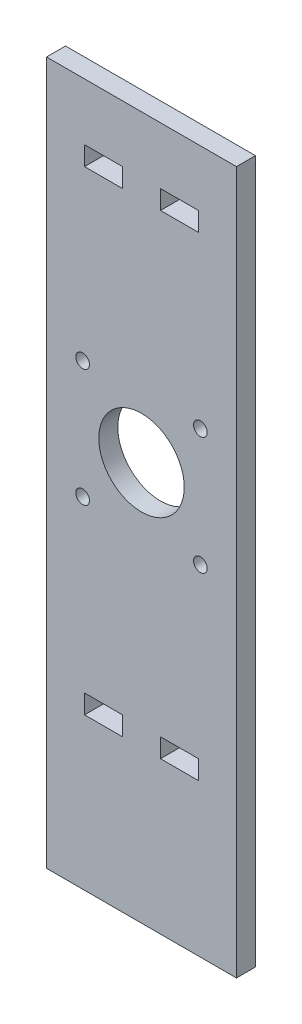
from build123d import *

# Parameters (mm, degrees)
SKETCH1_W           = 50
SKETCH1_H           = 185
SKETCH1_R           = 11.25
SKETCH1_R_2         = 1.8
SKETCH1_W_2         = 10
SKETCH1_H_2         = 5
BOSS_EXTRUDE1_DEPTH = 5


with BuildPart() as part:
    # Sketch1 → Boss-Extrude1 (new body)
    with BuildSketch(Plane.XY):
        with Locations((25, 92.5)):
            Rectangle(SKETCH1_W, SKETCH1_H)
        with Locations((25, 105)):
            Circle(SKETCH1_R, mode=Mode.SUBTRACT)
        with Locations((9.5, 120.5)):
            Circle(SKETCH1_R_2, mode=Mode.SUBTRACT)
        with Locations((9.5, 89.5)):
            Circle(SKETCH1_R_2, mode=Mode.SUBTRACT)
        with Locations((40.5, 89.5)):
            Circle(SKETCH1_R_2, mode=Mode.SUBTRACT)
        with Locations((40.5, 120.5)):
            Circle(SKETCH1_R_2, mode=Mode.SUBTRACT)
        with Locations((15, 167.5)):
            Rectangle(SKETCH1_W_2, SKETCH1_H_2, mode=Mode.SUBTRACT)
        with Locations((15, 42.5)):
            Rectangle(SKETCH1_W_2, SKETCH1_H_2, mode=Mode.SUBTRACT)
        with Locations((35, 42.5)):
            Rectangle(SKETCH1_W_2, SKETCH1_H_2, mode=Mode.SUBTRACT)
        with Locations((35, 167.5)):
            Rectangle(SKETCH1_W_2, SKETCH1_H_2, mode=Mode.SUBTRACT)
    extrude(amount=BOSS_EXTRUDE1_DEPTH)


solid = part.part
